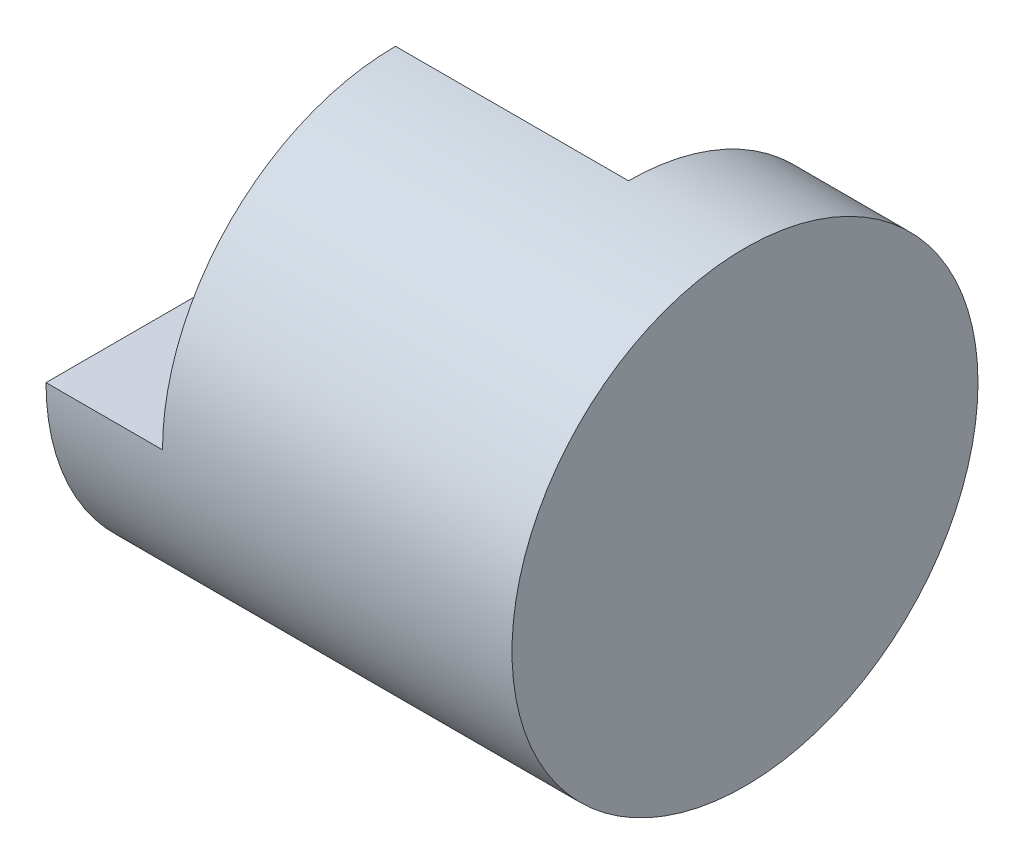
from build123d import *

# Parameters (mm, degrees)
SKETCH1_R           = 2
BOSS_EXTRUDE1_DEPTH = 2
CUT_EXTRUDE1_DEPTH  = 4


with BuildPart() as part:
    # Sketch1 → Boss-Extrude1 (new body, symmetric)
    with BuildSketch(Plane(origin=(0, 0, 0), x_dir=(0, 0, -1), z_dir=(1, 0, 0))):
        Circle(SKETCH1_R)
    extrude(amount=BOSS_EXTRUDE1_DEPTH, both=True)

    # Sketch3 → Cut-Extrude1 (cut)
    with BuildSketch(Plane(origin=(0, 0, 0), x_dir=(1, 0, 0), z_dir=(0, 1, 0))):
        Polygon((-1, 2), (1, 2), (1, 0), (-1, 0), (-1, -2), (-2, -2), (-2, 2), align=None)
    extrude(amount=CUT_EXTRUDE1_DEPTH, mode=Mode.SUBTRACT)


solid = part.part
